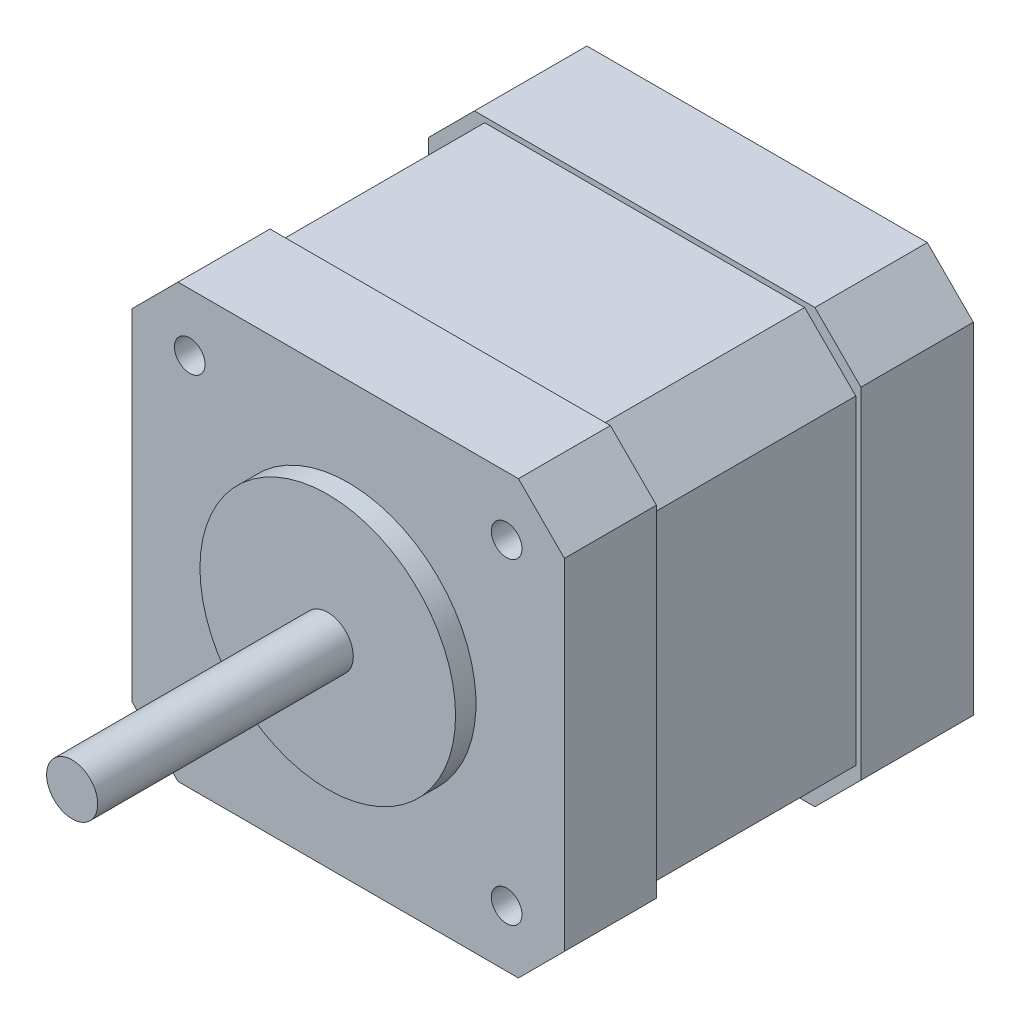
from build123d import *

# Parameters (mm, degrees)
ESQUISSE1_W             = 42.3
ESQUISSE1_H             = 42.3
BOSS_EXTRU_1_DEPTH      = 11
ESQUISSE2_W             = 41.3
ESQUISSE2_H             = 41.3
BOSS_EXTRU_2_DEPTH      = 20
ESQUISSE3_W             = 42.3
ESQUISSE3_H             = 42.3
BOSS_EXTRU_3_DEPTH      = 9
ESQUISSE4_R             = 12.5
BOSS_EXTRU_4_DEPTH      = 2
ESQUISSE5_R             = 2.5
BOSS_EXTRU_5_DEPTH      = 25
ESQUISSE6_R             = 1.5
ENL_V_MAT_EXTRU_1_DEPTH = 15
CHANFREIN2_SIZE         = 5
CHANFREIN3_SIZE         = 4.5


with BuildPart() as part:
    # Esquisse1 → Boss.-Extru.1 (new body)
    with BuildSketch(Plane.XY):
        with Locations((21.15, 21.15)):
            Rectangle(ESQUISSE1_W, ESQUISSE1_H)
    extrude(amount=BOSS_EXTRU_1_DEPTH)

    # Esquisse2 → Boss.-Extru.2 (add)
    with BuildSketch(Plane.XY.offset(11)):
        with Locations((21.15, 21.15)):
            Rectangle(ESQUISSE2_W, ESQUISSE2_H)
    extrude(amount=BOSS_EXTRU_2_DEPTH)

    # Esquisse3 → Boss.-Extru.3 (add)
    with BuildSketch(Plane.XY.offset(31)):
        with Locations((21.15, 21.15)):
            Rectangle(ESQUISSE3_W, ESQUISSE3_H)
    extrude(amount=BOSS_EXTRU_3_DEPTH)

    # Esquisse4 → Boss.-Extru.4 (add)
    with BuildSketch(Plane.XY.offset(40)):
        with Locations(Location((21.15, 21.15, 0), (0, 0, 180))):  # turned: the seam where the file's is
            Circle(ESQUISSE4_R)
    extrude(amount=BOSS_EXTRU_4_DEPTH)

    # Esquisse5 → Boss.-Extru.5 (add)
    with BuildSketch(Plane.XY.offset(42)):
        with Locations((21.15, 21.15)):
            Circle(ESQUISSE5_R)
    extrude(amount=BOSS_EXTRU_5_DEPTH)

    # Esquisse6 → Enlèv. mat.-Extru.1 (cut)
    with BuildSketch(Plane.XY.offset(40)):
        with Locations((5.65, 36.65)):
            Circle(ESQUISSE6_R)
        with Locations((5.65, 5.65)):
            Circle(ESQUISSE6_R)
        with Locations((36.65, 5.536437172)):
            Circle(ESQUISSE6_R)
        with Locations((36.65, 36.536437172)):
            Circle(ESQUISSE6_R)
    extrude(amount=-ENL_V_MAT_EXTRU_1_DEPTH, mode=Mode.SUBTRACT)

    # Chanfrein2
    chanfrein2_edges = [part.edges().sort_by_distance(p)[0] for p in [
        (0.5, 41.8, 21),
        (0.5, 0.5, 21),
        (41.8, 0.5, 21),
        (41.8, 41.8, 21),
    ]]
    chamfer(chanfrein2_edges, length=CHANFREIN2_SIZE)

    # Chanfrein3
    chanfrein3_edges = [part.edges().sort_by_distance(p)[0] for p in [
        (0, 42.3, 35.5),
        (0, 0, 35.5),
        (42.3, 0, 35.5),
        (42.3, 42.3, 35.5),
        (0, 42.3, 5.5),
        (42.3, 42.3, 5.5),
        (42.3, 0, 5.5),
        (0, 0, 5.5),
    ]]
    chamfer(chanfrein3_edges, length=CHANFREIN3_SIZE)


solid = part.part
